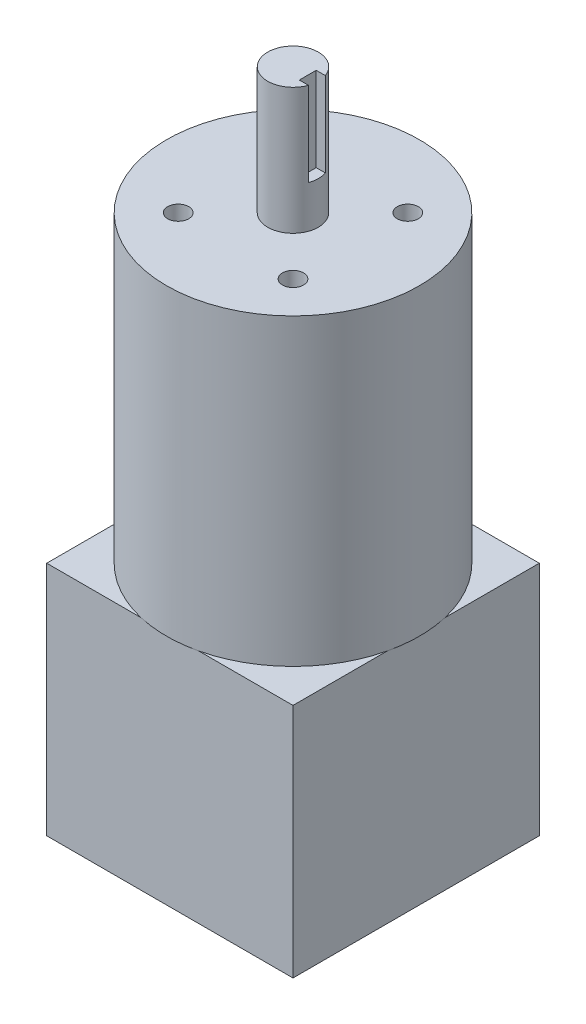
from build123d import *

# Parameters (mm, degrees)
SKETCH1_W           = 58.42
SKETCH1_H           = 58.42
BOSS_EXTRUDE1_DEPTH = 56
SKETCH2_R           = 30
BOSS_EXTRUDE2_DEPTH = 72
SKETCH3_R           = 6
BOSS_EXTRUDE3_DEPTH = 30
SKETCH4_R           = 2.5
CUT_EXTRUDE1_DEPTH  = 25.4
SKETCH5_W           = 2.5
SKETCH5_H           = 4
CUT_EXTRUDE2_DEPTH  = 20


with BuildPart() as part:
    # Sketch1 → Boss-Extrude1 (new body)
    with BuildSketch(Plane(origin=(0, 0, 0), x_dir=(1, 0, 0), z_dir=(0, 1, 0))):
        Rectangle(SKETCH1_W, SKETCH1_H)
    extrude(amount=BOSS_EXTRUDE1_DEPTH)

    # Sketch2 → Boss-Extrude2 (add)
    with BuildSketch(Plane(origin=(0, 56, 0), x_dir=(1, 0, 0), z_dir=(0, 1, 0))):
        Circle(SKETCH2_R)
    extrude(amount=BOSS_EXTRUDE2_DEPTH)

    # Sketch3 → Boss-Extrude3 (add)
    with BuildSketch(Plane(origin=(0, 128, 0), x_dir=(1, 0, 0), z_dir=(0, 1, 0))):
        Circle(SKETCH3_R)
    extrude(amount=BOSS_EXTRUDE3_DEPTH)

    # Sketch4 → Cut-Extrude1 (cut)
    with BuildSketch(Plane(origin=(0, 128, 0), x_dir=(1, 0, 0), z_dir=(0, 1, 0))):
        with Locations((-13.611805538, 13.611805538)):
            Circle(SKETCH4_R)
        with Locations((13.611805538, 13.611805538)):
            Circle(SKETCH4_R)
        with Locations((13.611805538, -13.611805538)):
            Circle(SKETCH4_R)
        with Locations((-13.611805538, -13.611805538)):
            Circle(SKETCH4_R)
    extrude(amount=-CUT_EXTRUDE1_DEPTH, mode=Mode.SUBTRACT)

    # Sketch5 → Cut-Extrude2 (cut)
    with BuildSketch(Plane(origin=(0, 158, 0), x_dir=(1, 0, 0), z_dir=(0, 1, 0))):
        with Locations((4.75, 0)):
            Rectangle(SKETCH5_W, SKETCH5_H)
    extrude(amount=-CUT_EXTRUDE2_DEPTH, mode=Mode.SUBTRACT)


solid = part.part
